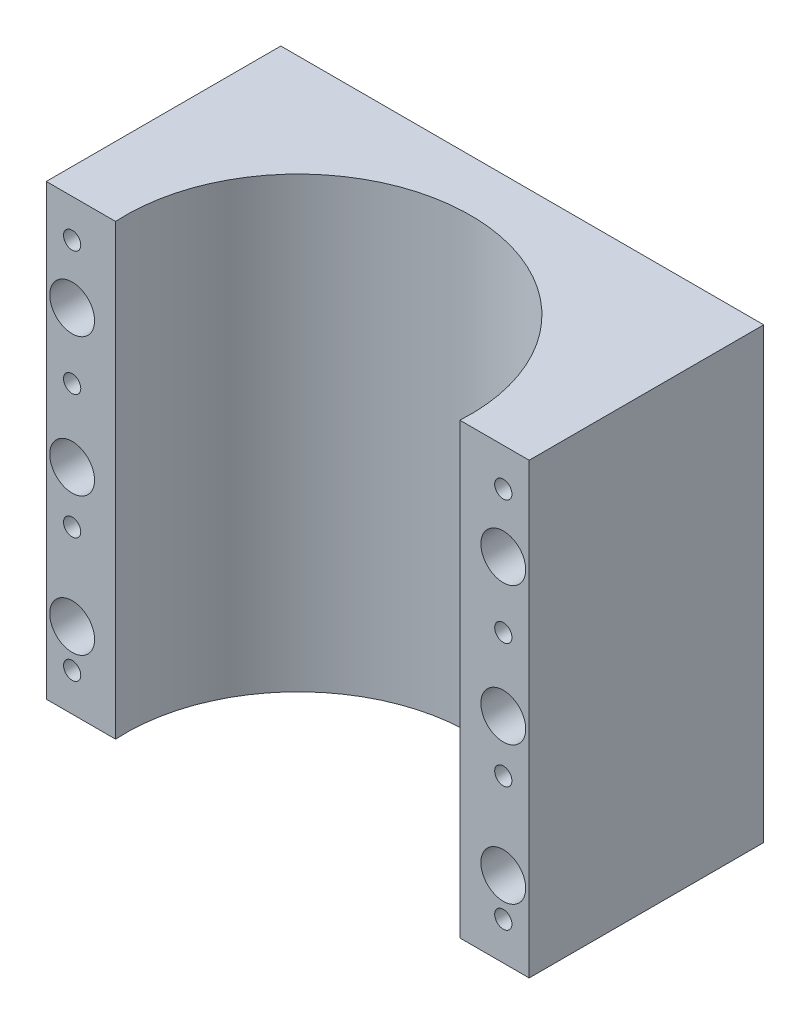
from build123d import *

# Parameters (mm, degrees)
SKETCH_1_W              = 140
SKETCH_1_H              = 130
EXTRUDE_1_DEPTH         = 68
SKETCH_2_R              = 50
CUT_EXTRUDE_2_DEPTH     = 131
SKETCH_3_R              = 6.5
CUT_EXTRUDE_3_DEPTH     = 35
SKETCH_4_R              = 4
CUT_EXTRUDE_4_DEPTH     = 34
HOLE_WIZARD_M6_10_D     = 5
HOLE_WIZARD_M6_10_DEPTH = 15
HOLE_WIZARD_M6_10_TIP   = 1.502151548


with BuildPart() as part:
    # 草图1 → 凸台-拉伸1 (new body)
    with BuildSketch(Plane.XY):
        with Locations((70, -65)):
            Rectangle(SKETCH_1_W, SKETCH_1_H)
    extrude(amount=EXTRUDE_1_DEPTH)

    # 草图2 → 切除-拉伸2 (cut, through all)
    with BuildSketch(Plane(origin=(0, 0, 0), x_dir=(1, 0, 0), z_dir=(0, 1, 0))):
        with Locations((70, -65)):
            Circle(SKETCH_2_R)
    extrude(amount=-CUT_EXTRUDE_2_DEPTH, mode=Mode.SUBTRACT)

    # 草图3 → 切除-拉伸3 (cut)
    with BuildSketch(Plane.XY.offset(68)):
        with Locations((7.5, -28)):
            Circle(SKETCH_3_R)
        with Locations((132.5, -28)):
            Circle(SKETCH_3_R)
        with Locations((132.5, -68)):
            Circle(SKETCH_3_R)
        with Locations((132.5, -108)):
            Circle(SKETCH_3_R)
        with Locations((7.5, -68)):
            Circle(SKETCH_3_R)
        with Locations((7.5, -108)):
            Circle(SKETCH_3_R)
    extrude(amount=-CUT_EXTRUDE_3_DEPTH, mode=Mode.SUBTRACT)

    # 草图4 → 切除-拉伸4 (cut, through all)
    with BuildSketch(Plane.XY.offset(33)):
        with Locations((132.5, -28)):
            Circle(SKETCH_4_R)
        with Locations((7.5, -28)):
            Circle(SKETCH_4_R)
        with Locations((132.5, -68)):
            Circle(SKETCH_4_R)
        with Locations((132.5, -108)):
            Circle(SKETCH_4_R)
        with Locations((7.5, -68)):
            Circle(SKETCH_4_R)
        with Locations((7.5, -108)):
            Circle(SKETCH_4_R)
    extrude(amount=-CUT_EXTRUDE_4_DEPTH, mode=Mode.SUBTRACT)

    # M6 螺纹孔10
    with Locations(Plane.XY.offset(68)):
        with Locations((7.5, -11), (7.5, -47), (7.5, -83), (132.5, -83), (132.5, -47), (132.5, -11), (7.5, -119), (132.5, -119)):
            Hole(HOLE_WIZARD_M6_10_D / 2, depth=HOLE_WIZARD_M6_10_DEPTH)
            with Locations((0, 0, -(HOLE_WIZARD_M6_10_DEPTH + HOLE_WIZARD_M6_10_TIP / 2))):  # 118° drill point
                Cone(0, HOLE_WIZARD_M6_10_D / 2, HOLE_WIZARD_M6_10_TIP, mode=Mode.SUBTRACT)


solid = part.part
